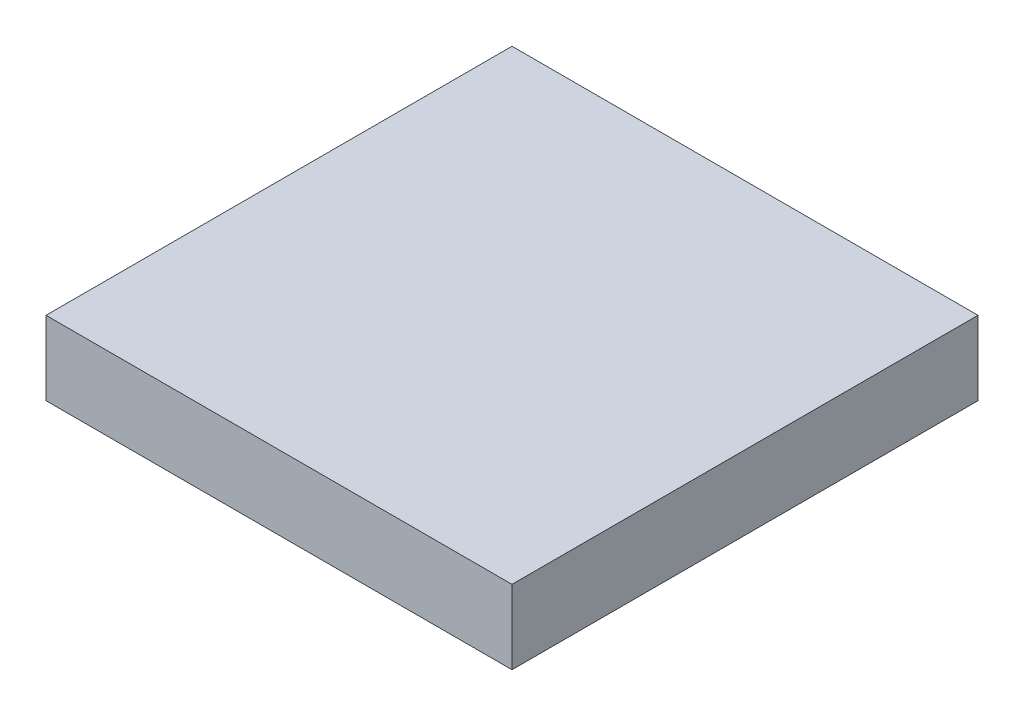
from build123d import *

# Parameters (mm, degrees)
SKETCH1_W           = 80.01
SKETCH1_H           = 80.01
BOSS_EXTRUDE1_DEPTH = 12.7


with BuildPart() as part:
    # Sketch1 → Boss-Extrude1 (new body)
    with BuildSketch(Plane(origin=(0, 0, 0), x_dir=(1, 0, 0), z_dir=(0, 1, 0))):
        with Locations((40.005, -40.005)):
            Rectangle(SKETCH1_W, SKETCH1_H)
    extrude(amount=BOSS_EXTRUDE1_DEPTH)


solid = part.part
